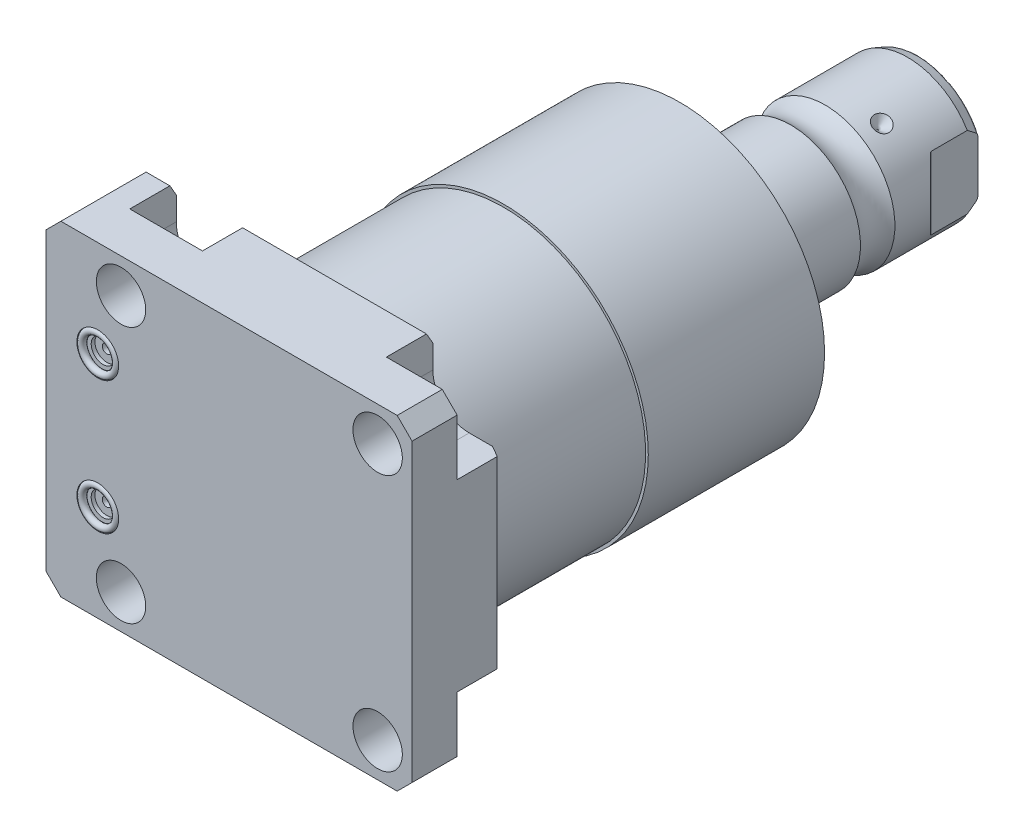
from build123d import *

# Parameters (mm, degrees)
SKETCH1_W                = 99.9998
SKETCH1_H                = 88.9
EXTRUDE1_DEPTH           = 25.019
SKETCH2_R                = 6.7437
CUT_EXTRUDE1_DEPTH       = 27.5209
LPATTERN1_COUNT          = 2
LPATTERN1_PITCH          = 70.104
LPATTERN1_COUNT_DIR2     = 2
LPATTERN1_PITCH_DIR2     = 70.104
CUT_EXTRUDE2_DEPTH       = 12.7
SKETCH6_R                = 5.7023
CUT_EXTRUDE3_DEPTH       = 1.4478
SKETCH7_R                = 3.2512
CUT_EXTRUDE4_DEPTH       = 1.016
SKETCH8_R                = 1.2446
CUT_EXTRUDE5_DEPTH       = 11.9888
SKETCH9_R                = 0.9271
LPATTERN3_COUNT          = 2
LPATTERN3_PITCH          = 36.2204
CHAMFER1_SIZE            = 4.064
CHAMFER2_SIZE            = 3.0226
CHAMFER2_SIZE2           = 1.745098924
SKETCH14_R               = 39.5224
EXTRUDE2_DEPTH           = 96.393
SKETCH15_OUTSIDE_W       = 138.19
SKETCH15_OUTSIDE_H       = 127.09
SKETCH15_OUTSIDE_R       = 38.7858
CUT_EXTRUDE9_DEPTH       = 44.45
CIRPATTERN1_COUNT        = 3
FILLET1_R                = 0.635
CUT_EXTRUDE12_DEPTH      = 45.45
CUT_EXTRUDE12_DEPTH_BACK = 45.45


with BuildPart() as part:
    # Sketch1 → Extrude1 (new body)
    with BuildSketch(Plane.XY):
        with Locations((-5.5499, 0)):
            Rectangle(SKETCH1_W, SKETCH1_H)
    extrude(amount=EXTRUDE1_DEPTH)

    # Sketch2 → Cut-Extrude1 (cut)
    with BuildSketch(Plane(origin=(0, 0, 0), x_dir=(-1, 0, 0), z_dir=(0, 0, -1))):
        with Locations((-35.052, -35.052)):
            Circle(SKETCH2_R)
    cut_extrude1 = extrude(amount=-CUT_EXTRUDE1_DEPTH, mode=Mode.SUBTRACT)

    # LPattern1: Cut-Extrude1 2 × 2
    with Locations(*[(-j * LPATTERN1_PITCH_DIR2, i * LPATTERN1_PITCH, 0) for i in range(LPATTERN1_COUNT) for j in range(LPATTERN1_COUNT_DIR2) if (i, j) != (0, 0)]):
        add(cut_extrude1, mode=Mode.SUBTRACT)

    # Sketch3 → Cut-Extrude2 (cut)
    with BuildSketch(Plane(origin=(0, 0, 0), x_dir=(-1, 0, 0), z_dir=(0, 0, -1))):
        with BuildLine():
            Line((-35.052, -25.1206), (-44.45, -25.1206))
            Line((-44.45, -25.1206), (-44.45, -44.45))
            Line((-44.45, -44.45), (-25.1206, -44.45))
            Line((-25.1206, -44.45), (-25.1206, -35.052))
            ThreePointArc((-25.1206, -35.052), (-28.029439713, -28.029439713), (-35.052, -25.1206))
        make_face()
        with BuildLine():
            Line((-44.45, 25.1206), (-44.45, 44.45))
            Line((-44.45, 44.45), (-25.1206, 44.45))
            Line((-25.1206, 44.45), (-25.1206, 35.052))
            ThreePointArc((-25.1206, 35.052), (-28.029439713, 28.029439713), (-35.052, 25.1206))
            Line((-35.052, 25.1206), (-44.45, 25.1206))
        make_face()
        with BuildLine():
            Line((25.1206, 44.45), (25.1206, 35.052))
            ThreePointArc((25.1206, 35.052), (35.052, 25.1206), (44.9834, 35.052))
            Line((44.9834, 35.052), (44.9834, 44.45))
            Line((44.9834, 44.45), (25.1206, 44.45))
        make_face()
        with BuildLine():
            Line((44.9834, -44.45), (25.1206, -44.45))
            Line((25.1206, -44.45), (25.1206, -35.052))
            ThreePointArc((25.1206, -35.052), (35.052, -25.1206), (44.9834, -35.052))
            Line((44.9834, -35.052), (44.9834, -44.45))
        make_face()
    extrude(amount=-CUT_EXTRUDE2_DEPTH, mode=Mode.SUBTRACT)

    # S2D0007 → Cut-Revolve1 (revolve, cut)
    with BuildSketch(Plane(origin=(-55.5498, -13.0048, 12.0142), x_dir=(0, 1, 0), z_dir=(0, 0, 1)), mode=Mode.PRIVATE) as cut_revolve1_sk:
        Polygon((0, 0), (10.4775, 0), (10.4775, -0.254), (6.1849, -0.254), (5.642306865, -2.8067), (4.9784, -3.470606865), (4.9784, -14.224), (0, -14.224), align=None)
    revolve(cut_revolve1_sk.sketch.rotate(Axis((-40.6146, -13.0048, 12.0142), (-1, 0, 0)), 90), axis=Axis((-40.6146, -13.0048, 12.0142), (-1, 0, 0)), mode=Mode.SUBTRACT)  # turned: the seam where the file's is

    # Sketch5 → Cut-Revolve2 (revolve, cut)
    with BuildSketch(Plane(origin=(-55.5498, 13.0048, 12.0142), x_dir=(0, 1, 0), z_dir=(0, 0, 1)), mode=Mode.PRIVATE) as cut_revolve2_sk:
        Polygon((0, 0), (10.4775, 0), (10.4775, -0.254), (6.1849, -0.254), (5.642306865, -2.8067), (4.9784, -3.470606865), (4.9784, -14.224), (0, -14.224), align=None)
    revolve(cut_revolve2_sk.sketch.rotate(Axis((-40.6146, 13.0048, 12.0142), (-1, 0, 0)), 90), axis=Axis((-40.6146, 13.0048, 12.0142), (-1, 0, 0)), mode=Mode.SUBTRACT)  # turned: the seam where the file's is

    # Sketch6 → Cut-Extrude3 (cut)
    with BuildSketch(Plane.XY.offset(25.019)):
        with Locations((-41.402, -18.1102)):
            Circle(SKETCH6_R)
        with Locations((-41.402, 18.1102)):
            Circle(SKETCH6_R)
    extrude(amount=-CUT_EXTRUDE3_DEPTH, mode=Mode.SUBTRACT)

    # Sketch7 → Cut-Extrude4 (cut)
    with BuildSketch(Plane.XY.offset(23.5712)):
        with Locations((-41.402, 18.1102)):
            Circle(SKETCH7_R)
        with Locations((-41.402, -18.1102)):
            Circle(SKETCH7_R)
    extrude(amount=-CUT_EXTRUDE4_DEPTH, mode=Mode.SUBTRACT)

    # Sketch8 → Cut-Extrude5 (cut)
    with BuildSketch(Plane.XY.offset(22.5552)):
        with Locations((-41.402, 18.1102)):
            Circle(SKETCH8_R)
        with Locations((-41.402, -18.1102)):
            Circle(SKETCH8_R)
    extrude(amount=-CUT_EXTRUDE5_DEPTH, mode=Mode.SUBTRACT)

    # Chamfer1
    chamfer1_edges = [part.edges().sort_by_distance(p)[0] for p in [
        (-55.5498, 44.45, 12.5095),
        (44.45, 44.45, 18.8595),
        (44.45, -44.45, 18.8595),
        (-55.5498, -44.45, 12.5095),
    ]]
    chamfer(chamfer1_edges, length=CHAMFER1_SIZE)

    # Chamfer2
    chamfer2_edges = [part.edges().sort_by_distance(p)[0] for p in [
        (-48.2346, -44.45, 0),
        (44.45, 0, 0),
        (0, 44.45, 0),
        (-48.2346, 44.45, 0),
        (0, -44.45, 0),
    ]]
    chamfer2_side = [part.faces().sort_by_distance(p)[0] for p in [
        (-6.590443221, 0, 0),
    ]]
    chamfer(chamfer2_edges, length=CHAMFER2_SIZE, length2=CHAMFER2_SIZE2, reference=chamfer2_side[0])

    # Sketch14 → Extrude2 (add)
    with BuildSketch(Plane(origin=(0, 0, 0), x_dir=(-1, 0, 0), z_dir=(0, 0, -1))):
        Circle(SKETCH14_R)
    extrude(amount=EXTRUDE2_DEPTH)

    # Sketch15 outside → Cut-Extrude9 (cut)
    with BuildSketch(Plane(origin=(0, 0, 0), x_dir=(-1, 0, 0), z_dir=(0, 0, -1))):
        with Locations((5.55, 0)):
            Rectangle(SKETCH15_OUTSIDE_W, SKETCH15_OUTSIDE_H)
        Circle(SKETCH15_OUTSIDE_R, mode=Mode.SUBTRACT)
    extrude(amount=CUT_EXTRUDE9_DEPTH, mode=Mode.SUBTRACT)

    # Sketch16 → Cut-Revolve3 (revolve, cut)
    with BuildSketch(Plane(origin=(0, 0, 0), x_dir=(0, 0, 1), z_dir=(1, 0, 0)), mode=Mode.PRIVATE) as cut_revolve3_sk:
        Polygon((-96.393, 25.4), (-92.608914325, 39.5224), (-96.393, 39.5224), align=None)
    revolve(cut_revolve3_sk.sketch.rotate(Axis((0, 0, -96.582204284), (0, 0, 1)), 270), axis=Axis((0, 0, -96.582204284), (0, 0, 1)), mode=Mode.SUBTRACT)  # turned: the seam where the file's is

    # Sketch17 → Revolve3 (revolve)
    with BuildSketch(Plane(origin=(0, 0, 0), x_dir=(0, 0, 1), z_dir=(1, 0, 0)), mode=Mode.PRIVATE) as revolve3_sk:
        with BuildLine():
            Line((-96.393, 0), (-96.393, 19.05))
            Line((-96.393, 19.05), (-122.87710643, 19.05))
            ThreePointArc((-122.87710643, 19.05), (-127.5842, 17.5006), (-132.29129357, 19.05))
            Line((-132.29129357, 19.05), (-154.8384, 19.05))
            Line((-154.8384, 19.05), (-157.7594, 17.986842946))
            Line((-157.7594, 17.986842946), (-157.7594, 0))
            Line((-157.7594, 0), (-96.393, 0))
        make_face()
    revolve(revolve3_sk.sketch.rotate(Axis((0, 0, -180.9369), (0, 0, 1)), 270), axis=Axis((0, 0, -180.9369), (0, 0, 1)))  # turned: the seam where the file's is

    # Sketch22 → Cut-Revolve4 (revolve, cut)
    with BuildSketch(Plane(origin=(0, 0, 0), x_dir=(1, 0, 0), z_dir=(0, 1, 0)), mode=Mode.PRIVATE) as cut_revolve4_sk:
        Polygon((-19.05, 140.6652), (-16.637, 138.2522), (-19.05, 138.2522), align=None)
    cut_revolve4 = revolve(cut_revolve4_sk.sketch.rotate(Axis((-42.100308337, 0, -138.2522), (1, 0, 0)), 180), axis=Axis((-42.100308337, 0, -138.2522), (1, 0, 0)), mode=Mode.SUBTRACT)  # turned: the seam where the file's is

    # CirPattern1: Cut-Revolve4 ×3 about axis
    cirpattern1_axis = Axis((0, 0, -180.9369), (0, 0, -1))
    for i in range(1, CIRPATTERN1_COUNT):
        add(cut_revolve4.rotate(cirpattern1_axis, i * 360 / CIRPATTERN1_COUNT), mode=Mode.SUBTRACT)

    # Fillet1
    fillet1_edges = [part.edges().sort_by_distance(p)[0] for p in [
        (17.986842946, 0, -157.7594),
    ]]
    fillet(fillet1_edges, radius=FILLET1_R)

    # Sketch24 → Hole1 (revolve, cut)
    with BuildSketch(Plane(origin=(0, 0, -157.7594), x_dir=(0, 1, 0), z_dir=(1, 0, 0))):
        Polygon((0, 0), (0, 25.399999974), (6.9342, 21.23351227), (6.9342, 0), align=None)
    revolve(axis=Axis((0, 0, -162.003599587), (0, 0, 1)), mode=Mode.SUBTRACT)

    # Sketch26 → Cut-Extrude12 (cut, two sides)
    with BuildSketch(Plane(origin=(0, 0, 0), x_dir=(1, 0, 0), z_dir=(0, 1, 0))) as cut_extrude12_sk:
        with BuildLine():
            Line((-16.2814, 157.7594), (-16.2814, 145.0594))
            ThreePointArc((-16.2814, 145.0594), (-16.339403796, 144.767795225), (-16.504584633, 144.520584633))
            Line((-16.504584633, 144.520584633), (-19.05, 141.975169265))
            Line((-19.05, 141.975169265), (-19.05, 157.7594))
            Line((-19.05, 157.7594), (-16.2814, 157.7594))
        make_face()
        with BuildLine():
            Line((19.05, 157.7594), (16.2814, 157.7594))
            Line((16.2814, 157.7594), (16.2814, 145.0594))
            ThreePointArc((16.2814, 145.0594), (16.339403796, 144.767795225), (16.504584633, 144.520584633))
            Line((16.504584633, 144.520584633), (19.05, 141.975169265))
            Line((19.05, 141.975169265), (19.05, 157.7594))
        make_face()
    extrude(amount=CUT_EXTRUDE12_DEPTH, mode=Mode.SUBTRACT)
    extrude(cut_extrude12_sk.sketch, amount=-CUT_EXTRUDE12_DEPTH_BACK, mode=Mode.SUBTRACT)


with BuildPart() as body_2:
    # Sketch9 → Revolve1 (revolve)
    with BuildSketch(Plane(origin=(-41.656, 18.1102, 23.5712), x_dir=(1, 0, 0), z_dir=(0, 1, 0))):
        with Locations((5.0292, -0.9271)):
            Circle(SKETCH9_R)
    revolve(axis=Axis((-41.402, 18.1102, 25.51811), (0, 0, -1)))


with BuildPart() as lpattern3_1:
    # LPattern3: pattern copy
    add(body_2.part.moved(Location(Vector(0, -1, 0) * (1 * LPATTERN3_PITCH))))


solid = Compound([part.part, body_2.part, lpattern3_1.part])
